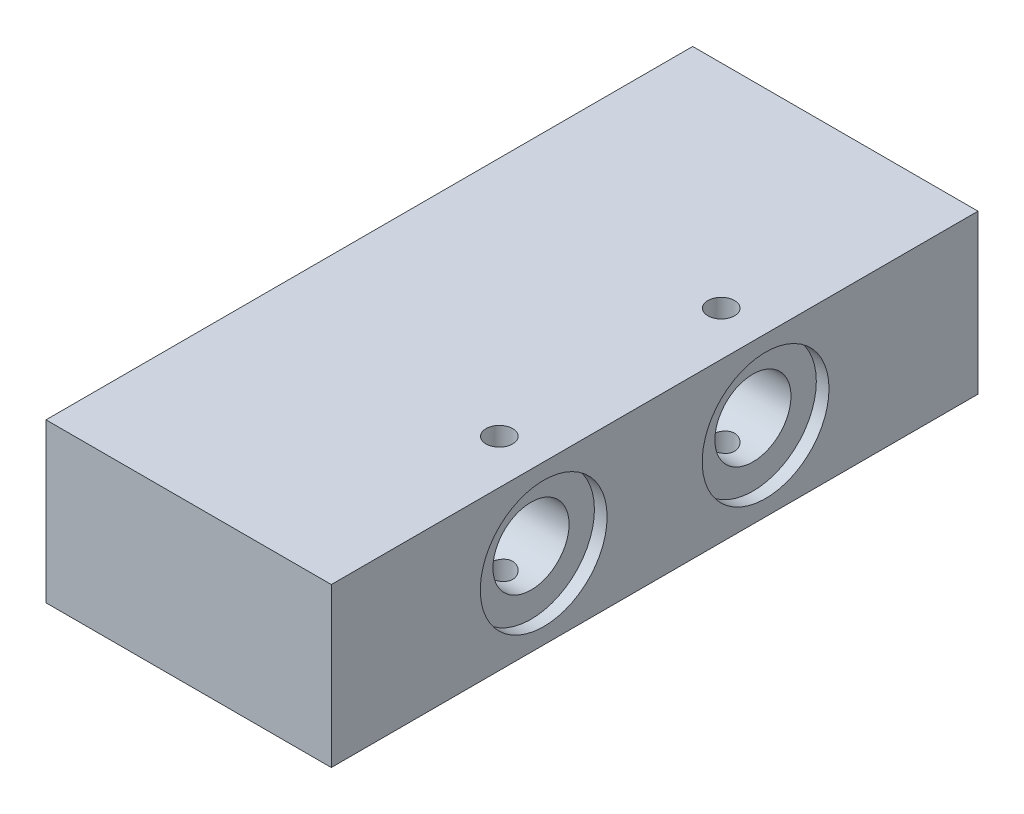
from build123d import *

# Parameters (mm, degrees)
SKETCH1_W             = 45
SKETCH1_H             = 102
BOSS_EXTRUDE1_DEPTH   = 25
M5_TAPPED_HOLE3_D     = 4.2
SKETCH27_R            = 6
CUT_EXTRUDE1_DEPTH    = 74
SKETCH28_R            = 10
CUT_EXTRUDE3_DEPTH    = 2
SKETCH30_R            = 10
CUT_EXTRUDE4_DEPTH    = 2
M5_TAPPED_HOLE4_D     = 4.2
M5_TAPPED_HOLE4_DEPTH = 14
M5_TAPPED_HOLE4_TIP   = 1.2618073
M5_TAPPED_HOLE5_D     = 4.2
M5_TAPPED_HOLE5_DEPTH = 15
M5_TAPPED_HOLE5_TIP   = 1.2618073


with BuildPart() as part:
    # Sketch1 → Boss-Extrude1 (new body)
    with BuildSketch(Plane(origin=(0, 0, 0), x_dir=(1, 0, 0), z_dir=(0, 1, 0))):
        Rectangle(SKETCH1_W, SKETCH1_H)
    extrude(amount=BOSS_EXTRUDE1_DEPTH)

    # M5 Tapped Hole3 (through all)
    with Locations(Plane(origin=(0, 25, 0), x_dir=(1, 0, 0), z_dir=(0, 1, 0))):
        with Locations((15.5, 17.5), (15.5, -17.5)):
            Hole(M5_TAPPED_HOLE3_D / 2)

    # Sketch27 → Cut-Extrude1 (cut)
    with BuildSketch(Plane.ZY.offset(22.5)):
        with Locations((-17.5, 12.5)):
            Circle(SKETCH27_R)
        with Locations((17.5, 12.5)):
            Circle(SKETCH27_R)
    extrude(amount=-CUT_EXTRUDE1_DEPTH, mode=Mode.SUBTRACT)

    # Sketch28 → Cut-Extrude3 (cut)
    with BuildSketch(Plane.ZY.offset(22.5)):
        with Locations((-17.5, 12.5)):
            Circle(SKETCH28_R)
        with Locations((17.5, 12.5)):
            Circle(SKETCH28_R)
    extrude(amount=-CUT_EXTRUDE3_DEPTH, mode=Mode.SUBTRACT)

    # Sketch30 → Cut-Extrude4 (cut)
    with BuildSketch(Plane(origin=(22.5, 0, 0), x_dir=(0, 0, -1), z_dir=(1, 0, 0))):
        with Locations((-17.5, 12.5)):
            Circle(SKETCH30_R)
        with Locations((17.5, 12.5)):
            Circle(SKETCH30_R)
    extrude(amount=-CUT_EXTRUDE4_DEPTH, mode=Mode.SUBTRACT)

    # M5 Tapped Hole4
    with Locations(Plane(origin=(0, 0, -51), x_dir=(-1, 0, 0), z_dir=(0, 0, -1))):
        with Locations((-18, 5), (18, 20)):
            Hole(M5_TAPPED_HOLE4_D / 2, depth=M5_TAPPED_HOLE4_DEPTH)
            with Locations((0, 0, -(M5_TAPPED_HOLE4_DEPTH + M5_TAPPED_HOLE4_TIP / 2))):  # 118° drill point
                Cone(0, M5_TAPPED_HOLE4_D / 2, M5_TAPPED_HOLE4_TIP, mode=Mode.SUBTRACT)

    # M5 Tapped Hole5
    with Locations(Plane.ZY.offset(22.5)):
        with Locations((0, 12.5)):
            Hole(M5_TAPPED_HOLE5_D / 2, depth=M5_TAPPED_HOLE5_DEPTH)
            with Locations((0, 0, -(M5_TAPPED_HOLE5_DEPTH + M5_TAPPED_HOLE5_TIP / 2))):  # 118° drill point
                Cone(0, M5_TAPPED_HOLE5_D / 2, M5_TAPPED_HOLE5_TIP, mode=Mode.SUBTRACT)


solid = part.part
